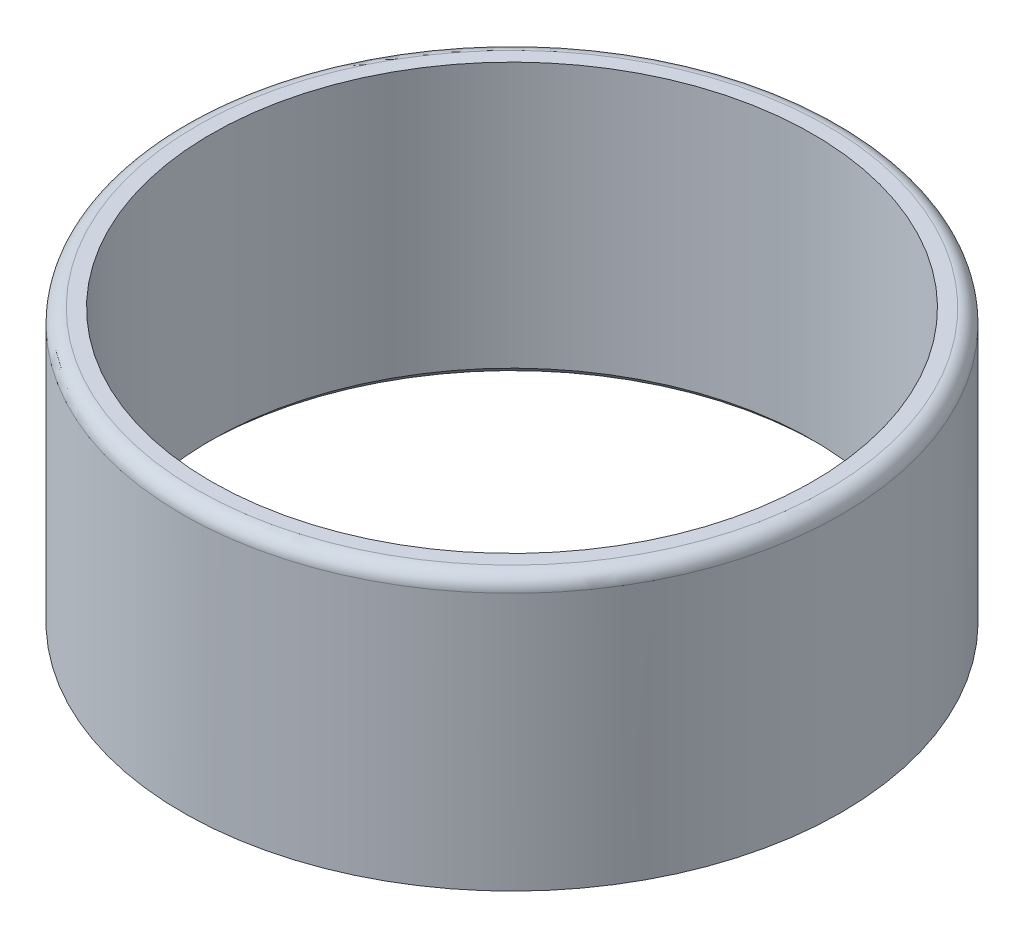
from build123d import *

# Parameters (mm, degrees)
SKETCH1_R           = 23
SKETCH1_R_2         = 21
EXTRUDE_THIN1_DEPTH = 19
FILLET1_R           = 1
CHAMFER1_SIZE       = 0.5


with BuildPart() as part:
    # Sketch1 → Extrude-Thin1 (new body)
    with BuildSketch(Plane(origin=(0, 0, 0), x_dir=(1, 0, 0), z_dir=(0, 1, 0))):
        Circle(SKETCH1_R)
        Circle(SKETCH1_R_2, mode=Mode.SUBTRACT)
    extrude(amount=EXTRUDE_THIN1_DEPTH)

    # Fillet1
    fillet1_edges = [part.edges().sort_by_distance(p)[0] for p in [
        (-23, 19, 0),
    ]]
    fillet(fillet1_edges, radius=FILLET1_R)

    # Chamfer1
    chamfer1_edges = [part.edges().sort_by_distance(p)[0] for p in [
        (-21, 0, 0),
    ]]
    chamfer(chamfer1_edges, length=CHAMFER1_SIZE)


solid = part.part
